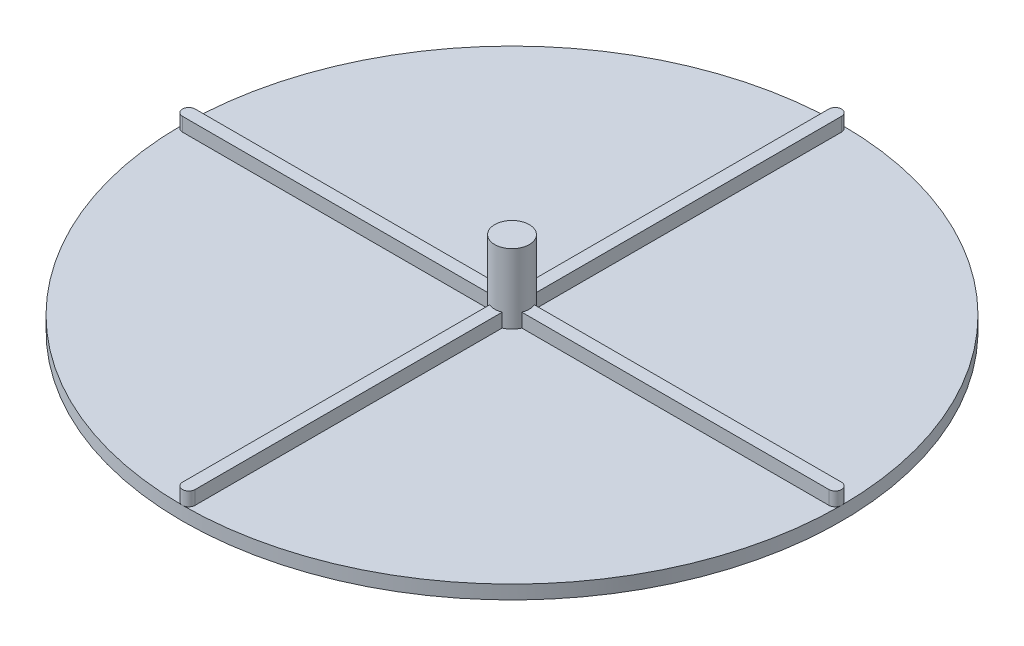
from build123d import *

# Parameters (mm, degrees)
SKETCH1_R                = 76.2
BOSS_EXTRUDE1_DEPTH      = 3.175
BOSS_EXTRUDE2_DEPTH      = 3.175
SKETCH3_R                = 4
BOSS_EXTRUDE3_DEPTH      = 12.954
BOSS_EXTRUDE3_DEPTH_BACK = 6.35


with BuildPart() as part:
    # Sketch1 → Boss-Extrude1 (new body)
    with BuildSketch(Plane(origin=(0, 0, 0), x_dir=(1, 0, 0), z_dir=(0, 1, 0))):
        Circle(SKETCH1_R)
    extrude(amount=BOSS_EXTRUDE1_DEPTH)

    # Sketch2 → Boss-Extrude2 (add)
    with BuildSketch(Plane(origin=(0, 3.175, 0), x_dir=(1, 0, 0), z_dir=(0, 1, 0))):
        with BuildLine():
            Line((-74.7395, 1.4605), (74.7395, 1.4605))
            ThreePointArc((74.7395, 1.4605), (76.2, 0), (74.7395, -1.4605))
            Line((74.7395, -1.4605), (-74.7395, -1.4605))
            ThreePointArc((-74.7395, -1.4605), (-76.2, 0), (-74.7395, 1.4605))
        make_face()
        with BuildLine():
            Line((1.4605, 74.7395), (1.4605, -74.7395))
            ThreePointArc((1.4605, -74.7395), (0, -76.2), (-1.4605, -74.7395))
            Line((-1.4605, -74.7395), (-1.4605, 74.7395))
            ThreePointArc((-1.4605, 74.7395), (0, 76.2), (1.4605, 74.7395))
        make_face()
    extrude(amount=BOSS_EXTRUDE2_DEPTH)

    # Sketch3 → Boss-Extrude3 (add, two sides)
    with BuildSketch(Plane(origin=(0, 6.35, 0), x_dir=(1, 0, 0), z_dir=(0, 1, 0))) as boss_extrude3_sk:
        Circle(SKETCH3_R)
    extrude(amount=BOSS_EXTRUDE3_DEPTH)
    extrude(boss_extrude3_sk.sketch, amount=-BOSS_EXTRUDE3_DEPTH_BACK)


solid = part.part
